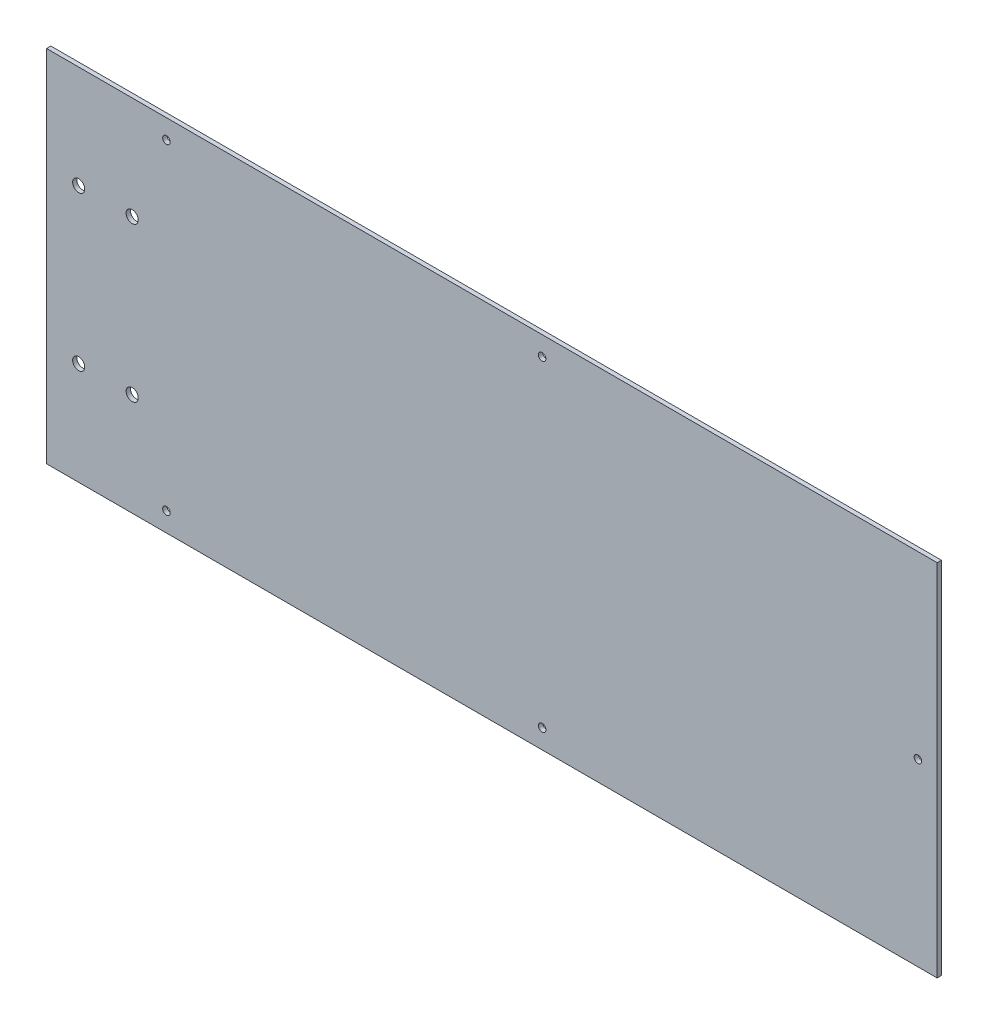
from build123d import *

# Parameters (mm, degrees)
SKETCH1_W           = 330.2
SKETCH1_H           = 133.35
SKETCH1_R           = 1.397
SKETCH1_R_2         = 2.2479
BOSS_EXTRUDE1_DEPTH = 1.5875


with BuildPart() as part:
    # Sketch1 → Boss-Extrude1 (new body)
    with BuildSketch(Plane.XY):
        with Locations((165.1, 66.675)):
            Rectangle(SKETCH1_W, SKETCH1_H)
        with Locations((323.0626, 66.675)):
            Circle(SKETCH1_R, mode=Mode.SUBTRACT)
        with Locations((183.7436, 126.2126)):
            Circle(SKETCH1_R, mode=Mode.SUBTRACT)
        with Locations((44.45, 126.2126)):
            Circle(SKETCH1_R, mode=Mode.SUBTRACT)
        with Locations((183.7436, 7.1374)):
            Circle(SKETCH1_R, mode=Mode.SUBTRACT)
        with Locations((44.45, 7.1374)):
            Circle(SKETCH1_R, mode=Mode.SUBTRACT)
        with Locations((11.9126, 95.25)):
            Circle(SKETCH1_R_2, mode=Mode.SUBTRACT)
        with Locations((11.9126, 38.1)):
            Circle(SKETCH1_R_2, mode=Mode.SUBTRACT)
        with Locations((31.75, 95.25)):
            Circle(SKETCH1_R_2, mode=Mode.SUBTRACT)
        with Locations((31.75, 38.1)):
            Circle(SKETCH1_R_2, mode=Mode.SUBTRACT)
    extrude(amount=BOSS_EXTRUDE1_DEPTH)


solid = part.part
